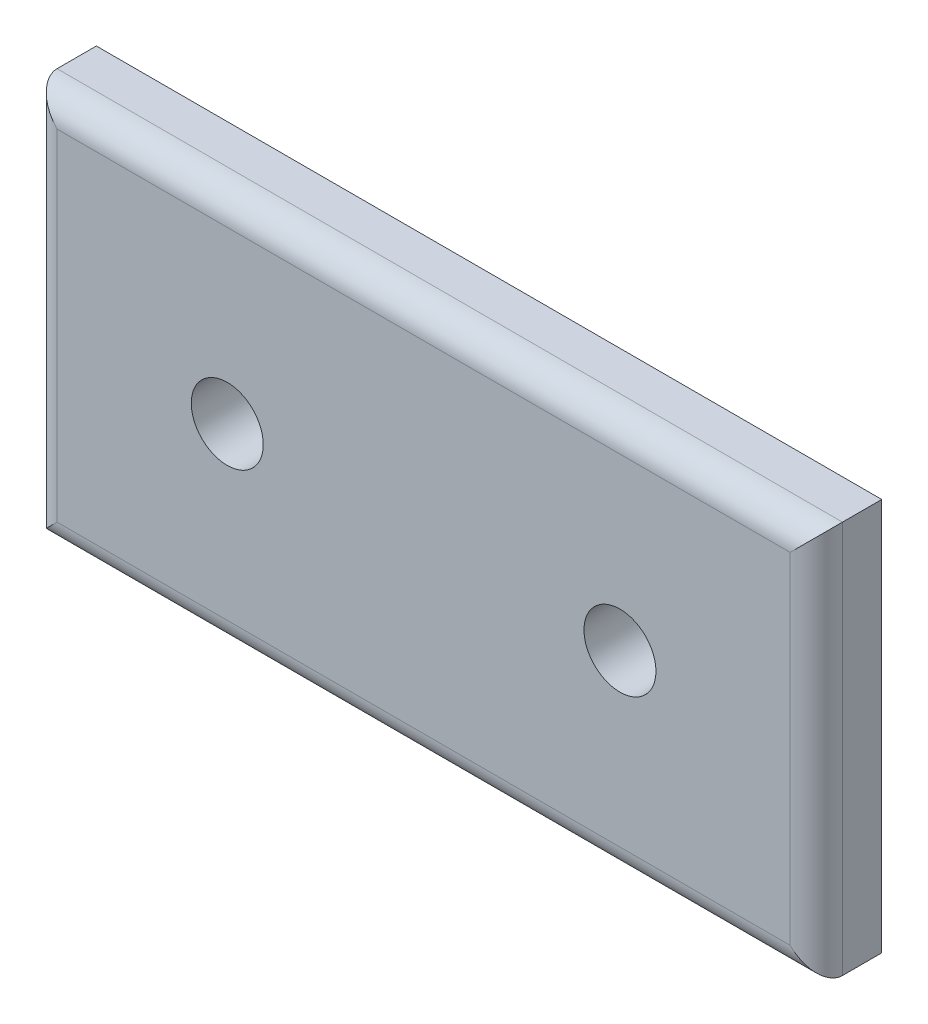
from build123d import *

# Parameters (mm, degrees)
SKETCH1_W           = 76.2
SKETCH1_H           = 38.1
BOSS_EXTRUDE1_DEPTH = 6.35
FILLET1_R           = 2.54
SKETCH2_R           = 3.4925
CUT_EXTRUDE1_DEPTH  = 6.35


with BuildPart() as part:
    # Sketch1 → Boss-Extrude1 (new body)
    with BuildSketch(Plane.XY):
        with Locations((38.1, 19.05)):
            Rectangle(SKETCH1_W, SKETCH1_H)
    extrude(amount=BOSS_EXTRUDE1_DEPTH)

    # Fillet1
    fillet1_edges = [part.edges().sort_by_distance(p)[0] for p in [
        (76.2, 19.05, 6.35),
        (38.1, 38.1, 6.35),
        (0, 19.05, 6.35),
        (38.1, 0, 6.35),
    ]]
    fillet(fillet1_edges, radius=FILLET1_R)

    # Sketch2 → Cut-Extrude1 (cut)
    with BuildSketch(Plane.XY.offset(6.35)):
        with Locations((19.05, 19.05)):
            Circle(SKETCH2_R)
        with Locations((57.15, 19.05)):
            Circle(SKETCH2_R)
    extrude(amount=-CUT_EXTRUDE1_DEPTH, mode=Mode.SUBTRACT)


solid = part.part
